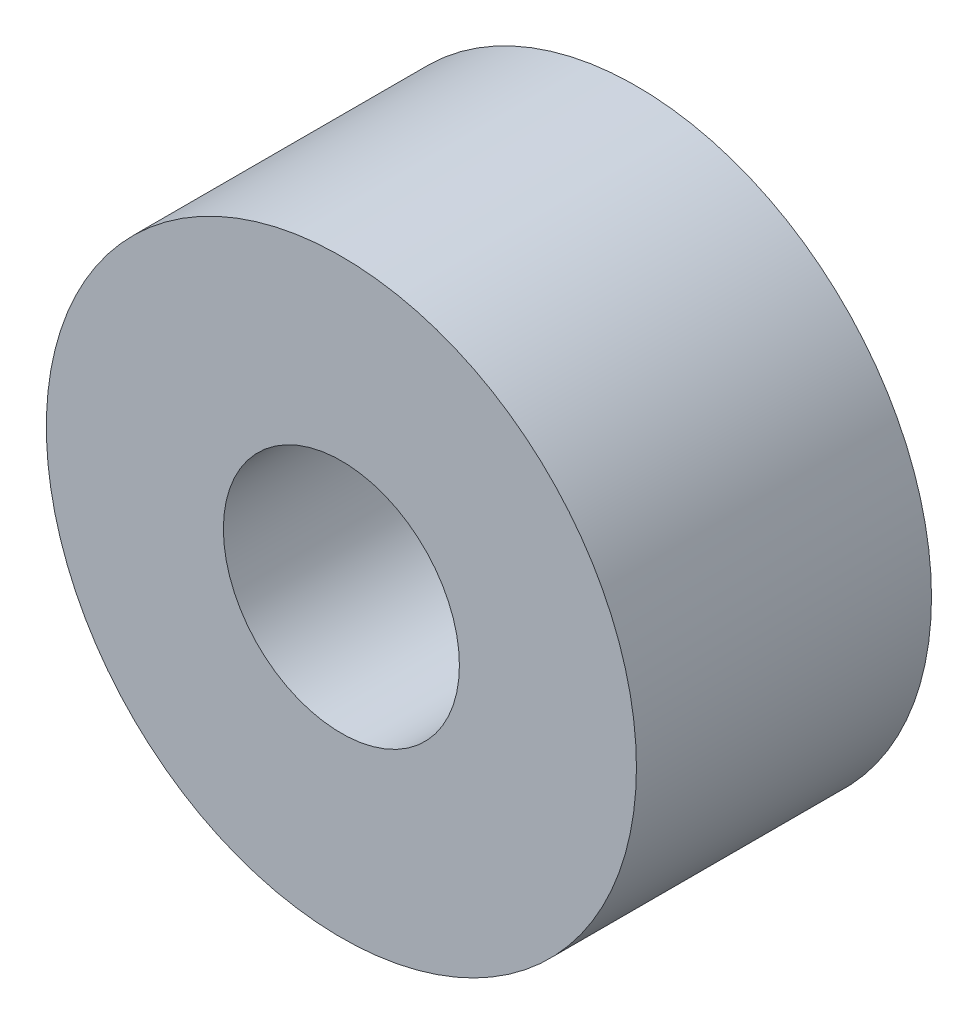
from build123d import *

# Parameters (mm, degrees)
MODEL_R                 = 2.5
SALIENTE_EXTRUIR1_DEPTH = 2.5
CROQUIS1_R              = 1
CORTAR_EXTRUIR1_DEPTH   = 10


with BuildPart() as part:
    # Model → Saliente-Extruir1 (new body)
    with BuildSketch(Plane.XY):
        with Locations((35.96, 18.866878764)):
            Circle(MODEL_R)
    extrude(amount=SALIENTE_EXTRUIR1_DEPTH)

    # Croquis1 → Cortar-Extruir1 (cut)
    with BuildSketch(Plane.XY.offset(2.5)):
        with Locations((35.96, 18.866878764)):
            Circle(CROQUIS1_R)
    extrude(amount=-CORTAR_EXTRUIR1_DEPTH, mode=Mode.SUBTRACT)


solid = part.part
